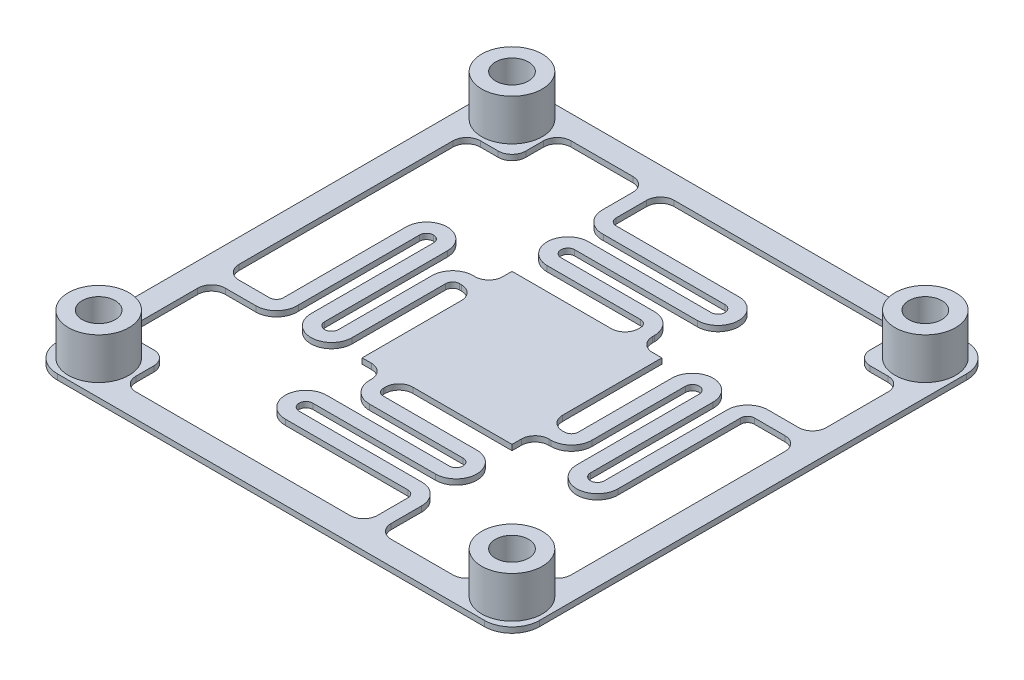
from build123d import *

# Parameters (mm, degrees)
SKETCH1_R           = 1.2
BOSS_EXTRUDE1_DEPTH = 0.4
SKETCH2_R           = 2.2
SKETCH2_R_2         = 1.2
BOSS_EXTRUDE2_DEPTH = 3
CUT_EXTRUDE1_DEPTH  = 3


with BuildPart() as part:
    # Sketch1 → Boss-Extrude1 (new body)
    with BuildSketch(Plane(origin=(0, 0, 0), x_dir=(1, 0, 0), z_dir=(0, 1, 0))):
        with BuildLine():
            Line((-10.894736842, 18.523391813), (20.105263158, 18.523391813))
            ThreePointArc((20.105263158, 18.523391813), (21.51947672, 17.937605375), (22.105263158, 16.523391813))
            Line((22.105263158, 16.523391813), (22.105263158, -14.476608187))
            ThreePointArc((22.105263158, -14.476608187), (21.51947672, -15.89082175), (20.105263158, -16.476608187))
            Line((20.105263158, -16.476608187), (-10.894736842, -16.476608187))
            ThreePointArc((-10.894736842, -16.476608187), (-12.308950404, -15.89082175), (-12.894736842, -14.476608187))
            Line((-12.894736842, -14.476608187), (-12.894736842, 16.523391813))
            ThreePointArc((-12.894736842, 16.523391813), (-12.308950404, 17.937605375), (-10.894736842, 18.523391813))
        make_face()
        with Locations((19.605263158, 16.023391813)):
            Circle(SKETCH1_R, mode=Mode.SUBTRACT)
        with Locations((-10.394736842, 16.023391813)):
            Circle(SKETCH1_R, mode=Mode.SUBTRACT)
        with Locations((-10.394736842, -13.976608187)):
            Circle(SKETCH1_R, mode=Mode.SUBTRACT)
        with Locations((19.605263158, -13.976608187)):
            Circle(SKETCH1_R, mode=Mode.SUBTRACT)
    extrude(amount=BOSS_EXTRUDE1_DEPTH)

    # Sketch2 → Boss-Extrude2 (add)
    with BuildSketch(Plane(origin=(0, 0.4, 0), x_dir=(1, 0, 0), z_dir=(0, 1, 0))):
        with Locations((-10.394736842, -13.976608187)):
            Circle(SKETCH2_R)
        with Locations((-10.394736842, -13.976608187)):
            Circle(SKETCH2_R_2, mode=Mode.SUBTRACT)
        with Locations((-10.394736842, 16.023391813)):
            Circle(SKETCH2_R)
        with Locations((-10.394736842, 16.023391813)):
            Circle(SKETCH2_R_2, mode=Mode.SUBTRACT)
        with Locations((19.605263158, 16.023391813)):
            Circle(SKETCH2_R)
        with Locations((19.605263158, 16.023391813)):
            Circle(SKETCH2_R_2, mode=Mode.SUBTRACT)
        with Locations((19.605263158, -13.976608187)):
            Circle(SKETCH2_R)
        with Locations((19.605263158, -13.976608187)):
            Circle(SKETCH2_R_2, mode=Mode.SUBTRACT)
    extrude(amount=BOSS_EXTRUDE2_DEPTH)

    # Sketch3 → Cut-Extrude1 (cut)
    with BuildSketch(Plane.XZ):
        with BuildLine():
            Line((-0.833589271, -2.785018417), (-0.833589271, 4.41546061))
            Line((-0.833589271, 4.41546061), (-0.156363438, 4.41546061))
            ThreePointArc((-0.156363438, 4.41546061), (0.550743343, 4.708353829), (0.843636562, 5.41546061))
            Line((0.843636562, 5.41546061), (0.843636562, 5.551805291))
            ThreePointArc((0.843636562, 5.551805291), (1.282976392, 6.612465467), (2.343636569, 7.051805294))
            Line((2.343636569, 7.051805294), (9.126090454, 7.051805294))
            ThreePointArc((9.126090454, 7.051805294), (9.479643844, 7.198251903), (9.626090454, 7.551805294))
            ThreePointArc((9.626090454, 7.551805294), (9.479643844, 7.905358684), (9.126090454, 8.051805294))
            Line((9.126090454, 8.051805294), (0.22587818, 8.051805294))
            ThreePointArc((0.22587818, 8.051805294), (-0.834781992, 8.491145122), (-1.27412182, 9.551805294))
            ThreePointArc((-1.27412182, 9.551805294), (-0.834781992, 10.612465466), (0.22587818, 11.051805294))
            Line((0.22587818, 11.051805294), (9.126090453, 11.051805294))
            ThreePointArc((9.126090453, 11.051805294), (9.479643844, 11.198251903), (9.626090453, 11.551805294))
            Line((9.626090453, 11.551805294), (9.626090453, 13.765231208))
            ThreePointArc((9.626090453, 13.765231208), (9.333197234, 14.472337989), (8.626090453, 14.765231208))
            Line((8.626090453, 14.765231208), (-6.894736834, 14.765231208))
            ThreePointArc((-6.894736834, 14.765231208), (-7.601843615, 14.472337989), (-7.894736834, 13.765231208))
            Line((-7.894736834, 13.765231208), (-7.894736834, 12.476608194))
            ThreePointArc((-7.894736834, 12.476608194), (-8.187630054, 11.769501409), (-8.89473684, 11.476608191))
            Line((-8.89473684, 11.476608191), (-10.183359869, 11.476608191))
            ThreePointArc((-10.183359869, 11.476608191), (-10.89046665, 11.183714972), (-11.183359869, 10.476608191))
            Line((-11.183359869, 10.476608191), (-11.183359869, 5.997435482))
            ThreePointArc((-11.183359869, 5.997435482), (-10.89046665, 5.290328701), (-10.183359869, 4.997435482))
            Line((-10.183359869, 4.997435482), (-7.969933954, 4.997435482))
            ThreePointArc((-7.969933954, 4.997435482), (-6.874458326, 4.522097937), (-6.473276958, 3.397346345))
            Line((-6.473276958, 3.397346345), (-6.473276958, -5.401665341))
            ThreePointArc((-6.473276958, -5.401665341), (-6.325715264, -5.756794495), (-5.969933957, -5.902776793))
            ThreePointArc((-5.969933957, -5.902776793), (-5.616380567, -5.756330184), (-5.469933957, -5.402776793))
            Line((-5.469933957, -5.402776793), (-5.469933957, 3.497435479))
            ThreePointArc((-5.469933957, 3.497435479), (-5.030594129, 4.558095651), (-3.969933957, 4.997435479))
            ThreePointArc((-3.969933957, 4.997435479), (-2.909273785, 4.558095651), (-2.469933957, 3.497435479))
            Line((-2.469933957, 3.497435479), (-2.469933957, -3.285018405))
            ThreePointArc((-2.469933957, -3.285018405), (-2.32348735, -3.638571805), (-1.969933952, -3.785018417))
            Line((-1.969933952, -3.785018417), (-1.833589271, -3.785018417))
            ThreePointArc((-1.833589271, -3.785018417), (-1.12648249, -3.492125198), (-0.833589271, -2.785018417))
        make_face()
        with BuildLine():
            Line((-1.969933952, -4.785018409), (-1.833589271, -4.785018409))
            ThreePointArc((-1.833589271, -4.785018409), (-1.12648249, -5.077911628), (-0.833589271, -5.785018409))
            Line((-0.833589271, -5.785018409), (-0.833589271, -6.462244242))
            Line((-0.833589271, -6.462244242), (6.366889757, -6.462244242))
            ThreePointArc((6.366889757, -6.462244242), (7.073996538, -6.75513746), (7.366889757, -7.462244242))
            Line((7.366889757, -7.462244242), (7.366889757, -7.598588923))
            ThreePointArc((7.366889757, -7.598588923), (7.220443145, -7.952142321), (6.866889744, -8.098588928))
            Line((6.866889744, -8.098588928), (0.08443586, -8.098588928))
            ThreePointArc((0.08443586, -8.098588928), (-0.976224312, -8.537928756), (-1.41556414, -9.598588928))
            ThreePointArc((-1.41556414, -9.598588928), (-0.976224312, -10.6592491), (0.08443586, -11.098588928))
            Line((0.08443586, -11.098588928), (8.984648133, -11.098588928))
            ThreePointArc((8.984648133, -11.098588928), (9.338201523, -11.245035537), (9.484648133, -11.598588928))
            ThreePointArc((9.484648133, -11.598588928), (9.338665835, -11.954370235), (8.983536681, -12.101931929))
            Line((8.983536681, -12.101931929), (0.184524995, -12.101931929))
            ThreePointArc((0.184524995, -12.101931929), (-0.940226598, -12.503113296), (-1.415564143, -13.598588925))
            Line((-1.415564143, -13.598588925), (-1.415564143, -15.812014839))
            ThreePointArc((-1.415564143, -15.812014839), (-1.708457362, -16.51912162), (-2.415564143, -16.812014839))
            Line((-2.415564143, -16.812014839), (-6.894736851, -16.812014839))
            ThreePointArc((-6.894736851, -16.812014839), (-7.601843632, -16.51912162), (-7.894736851, -15.812014839))
            Line((-7.894736851, -15.812014839), (-7.894736851, -14.52339181))
            ThreePointArc((-7.894736851, -14.52339181), (-8.187630069, -13.816285024), (-8.894736855, -13.523391805))
            Line((-8.894736855, -13.523391805), (-10.183359869, -13.523391805))
            ThreePointArc((-10.183359869, -13.523391805), (-10.89046665, -13.230498586), (-11.183359869, -12.523391805))
            Line((-11.183359869, -12.523391805), (-11.183359869, 2.997435482))
            ThreePointArc((-11.183359869, 2.997435482), (-10.89046665, 3.704542264), (-10.183359869, 3.997435482))
            Line((-10.183359869, 3.997435482), (-7.969933954, 3.997435482))
            ThreePointArc((-7.969933954, 3.997435482), (-7.616380564, 3.850988873), (-7.469933954, 3.497435482))
            Line((-7.469933954, 3.497435482), (-7.469933954, -5.402776791))
            ThreePointArc((-7.469933954, -5.402776791), (-7.030594126, -6.463436962), (-5.969933954, -6.902776791))
            ThreePointArc((-5.969933954, -6.902776791), (-4.909273782, -6.463436962), (-4.469933954, -5.402776791))
            Line((-4.469933954, -5.402776791), (-4.469933954, 3.497435483))
            ThreePointArc((-4.469933954, 3.497435483), (-4.323487345, 3.850988874), (-3.969933954, 3.997435483))
            ThreePointArc((-3.969933954, 3.997435483), (-3.616380564, 3.850988874), (-3.469933954, 3.497435483))
            Line((-3.469933954, 3.497435483), (-3.469933954, -3.285018402))
            ThreePointArc((-3.469933954, -3.285018402), (-3.030594127, -4.345678579), (-1.969933952, -4.785018409))
        make_face()
        with BuildLine():
            Line((2.843636554, 4.41546061), (10.044115581, 4.41546061))
            Line((10.044115581, 4.41546061), (10.044115581, 3.738234778))
            ThreePointArc((10.044115581, 3.738234778), (10.3370088, 3.031127996), (11.044115581, 2.738234778))
            Line((11.044115581, 2.738234778), (11.180460262, 2.738234778))
            ThreePointArc((11.180460262, 2.738234778), (12.241120438, 2.298894948), (12.680460265, 1.238234771))
            Line((12.680460265, 1.238234771), (12.680460265, -5.544219114))
            ThreePointArc((12.680460265, -5.544219114), (12.826906874, -5.897772505), (13.180460265, -6.044219114))
            ThreePointArc((13.180460265, -6.044219114), (13.534013655, -5.897772505), (13.680460265, -5.544219114))
            Line((13.680460265, -5.544219114), (13.680460265, 3.355993159))
            ThreePointArc((13.680460265, 3.355993159), (14.119800093, 4.416653331), (15.180460265, 4.855993159))
            ThreePointArc((15.180460265, 4.855993159), (16.241120436, 4.416653331), (16.680460265, 3.355993159))
            Line((16.680460265, 3.355993159), (16.680460265, -5.544219114))
            ThreePointArc((16.680460265, -5.544219114), (16.826906874, -5.897772504), (17.180460265, -6.044219114))
            Line((17.180460265, -6.044219114), (19.393886179, -6.044219114))
            ThreePointArc((19.393886179, -6.044219114), (20.10099296, -5.751325895), (20.393886179, -5.044219114))
            Line((20.393886179, -5.044219114), (20.393886179, 10.476608174))
            ThreePointArc((20.393886179, 10.476608174), (20.10099296, 11.183714955), (19.393886179, 11.476608174))
            Line((19.393886179, 11.476608174), (18.105263165, 11.476608174))
            ThreePointArc((18.105263165, 11.476608174), (17.39815638, 11.769501393), (17.105263161, 12.476608179))
            Line((17.105263161, 12.476608179), (17.105263161, 13.765231208))
            ThreePointArc((17.105263161, 13.765231208), (16.812369943, 14.472337989), (16.105263161, 14.765231208))
            Line((16.105263161, 14.765231208), (11.626090453, 14.765231208))
            ThreePointArc((11.626090453, 14.765231208), (10.918983672, 14.472337989), (10.626090453, 13.765231208))
            Line((10.626090453, 13.765231208), (10.626090453, 11.551805294))
            ThreePointArc((10.626090453, 11.551805294), (10.150752908, 10.456329665), (9.026001316, 10.055148298))
            Line((9.026001316, 10.055148298), (0.226989629, 10.055148298))
            ThreePointArc((0.226989629, 10.055148298), (-0.128139524, 9.907586603), (-0.274121822, 9.551805297))
            ThreePointArc((-0.274121822, 9.551805297), (-0.127675213, 9.198251906), (0.225878178, 9.051805297))
            Line((0.225878178, 9.051805297), (9.12609045, 9.051805297))
            ThreePointArc((9.12609045, 9.051805297), (10.186750622, 8.612465468), (10.62609045, 7.551805297))
            ThreePointArc((10.62609045, 7.551805297), (10.186750622, 6.491145125), (9.12609045, 6.051805297))
            Line((9.12609045, 6.051805297), (2.343636566, 6.051805297))
            ThreePointArc((2.343636566, 6.051805297), (1.990083166, 5.90535869), (1.843636554, 5.551805292))
            Line((1.843636554, 5.551805292), (1.843636554, 5.41546061))
            ThreePointArc((1.843636554, 5.41546061), (2.136529772, 4.708353829), (2.843636554, 4.41546061))
        make_face()
        with BuildLine():
            Line((10.044115581, 0.738234786), (10.044115581, -6.462244242))
            Line((10.044115581, -6.462244242), (9.366889748, -6.462244242))
            ThreePointArc((9.366889748, -6.462244242), (8.659782967, -6.75513746), (8.366889748, -7.462244242))
            Line((8.366889748, -7.462244242), (8.366889748, -7.598588922))
            ThreePointArc((8.366889748, -7.598588922), (7.927549919, -8.659249098), (6.866889742, -9.098588925))
            Line((6.866889742, -9.098588925), (0.084435857, -9.098588925))
            ThreePointArc((0.084435857, -9.098588925), (-0.269117534, -9.245035534), (-0.415564143, -9.598588925))
            ThreePointArc((-0.415564143, -9.598588925), (-0.269117534, -9.952142316), (0.084435857, -10.098588925))
            Line((0.084435857, -10.098588925), (8.98464813, -10.098588925))
            ThreePointArc((8.98464813, -10.098588925), (10.045308302, -10.537928753), (10.48464813, -11.598588925))
            ThreePointArc((10.48464813, -11.598588925), (10.045308302, -12.659249097), (8.98464813, -13.098588925))
            Line((8.98464813, -13.098588925), (0.084435857, -13.098588925))
            ThreePointArc((0.084435857, -13.098588925), (-0.269117533, -13.245035534), (-0.415564143, -13.598588925))
            Line((-0.415564143, -13.598588925), (-0.415564143, -15.812014839))
            ThreePointArc((-0.415564143, -15.812014839), (-0.122670924, -16.51912162), (0.584435857, -16.812014839))
            Line((0.584435857, -16.812014839), (16.105263144, -16.812014839))
            ThreePointArc((16.105263144, -16.812014839), (16.812369926, -16.51912162), (17.105263144, -15.812014839))
            Line((17.105263144, -15.812014839), (17.105263144, -14.523391826))
            ThreePointArc((17.105263144, -14.523391826), (17.398156364, -13.81628504), (18.10526315, -13.523391822))
            Line((18.10526315, -13.523391822), (19.393886179, -13.523391822))
            ThreePointArc((19.393886179, -13.523391822), (20.10099296, -13.230498603), (20.393886179, -12.523391822))
            Line((20.393886179, -12.523391822), (20.393886179, -8.044219114))
            ThreePointArc((20.393886179, -8.044219114), (20.10099296, -7.337112332), (19.393886179, -7.044219114))
            Line((19.393886179, -7.044219114), (17.180460265, -7.044219114))
            ThreePointArc((17.180460265, -7.044219114), (16.084984636, -6.568881569), (15.683803268, -5.444129976))
            Line((15.683803268, -5.444129976), (15.683803268, 3.35488171))
            ThreePointArc((15.683803268, 3.35488171), (15.536241574, 3.710010864), (15.180460267, 3.855993162))
            ThreePointArc((15.180460267, 3.855993162), (14.826906877, 3.709546552), (14.680460267, 3.355993162))
            Line((14.680460267, 3.355993162), (14.680460267, -5.544219111))
            ThreePointArc((14.680460267, -5.544219111), (14.241120439, -6.604879282), (13.180460267, -7.044219111))
            ThreePointArc((13.180460267, -7.044219111), (12.119800096, -6.604879282), (11.680460267, -5.544219111))
            Line((11.680460267, -5.544219111), (11.680460267, 1.238234774))
            ThreePointArc((11.680460267, 1.238234774), (11.534013661, 1.591788174), (11.180460263, 1.738234786))
            Line((11.180460263, 1.738234786), (11.044115581, 1.738234786))
            ThreePointArc((11.044115581, 1.738234786), (10.3370088, 1.445341567), (10.044115581, 0.738234786))
        make_face()
    extrude(amount=-CUT_EXTRUDE1_DEPTH, mode=Mode.SUBTRACT)


solid = part.part
